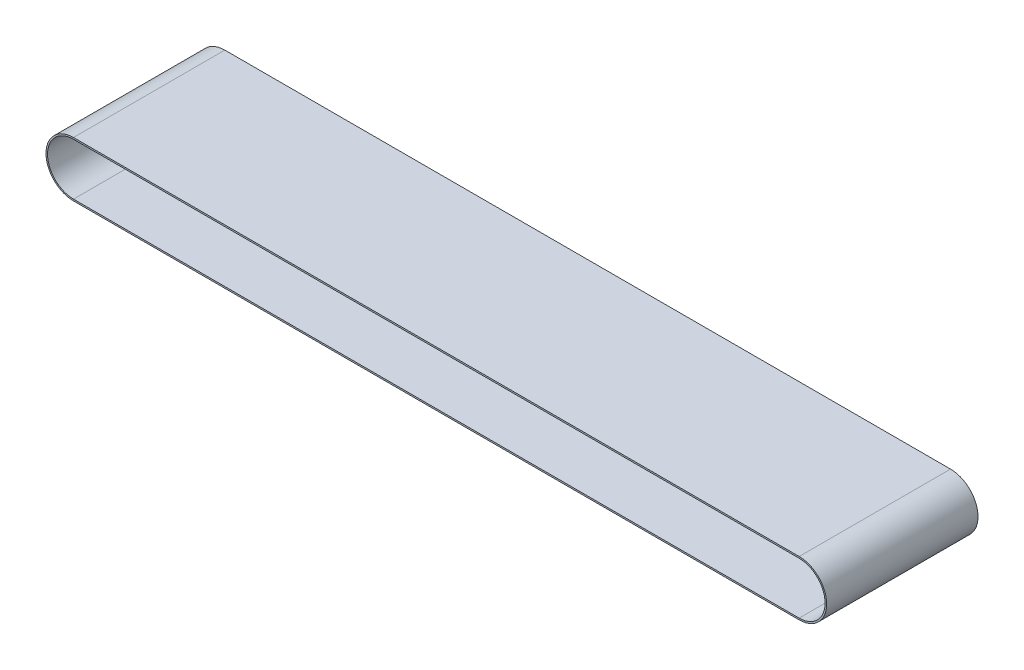
from build123d import *

# Parameters (mm, degrees)
BOSS_EXTRUDE1_DEPTH = 73


with BuildPart() as part:
    # Sketch1 → Boss-Extrude1 (new body, symmetric)
    with BuildSketch(Plane.XY):
        with BuildLine():
            Line((0, 26.5), (700, 26.5))
            ThreePointArc((700, 26.5), (726.5, 0), (700, -26.5))
            Line((700, -26.5), (0, -26.5))
            ThreePointArc((0, -26.5), (-26.5, 0), (0, 26.5))
        make_face()
        with BuildLine():
            Line((0, 25), (700, 25))
            ThreePointArc((700, 25), (725, 0), (700, -25))
            Line((700, -25), (0, -25))
            ThreePointArc((0, -25), (-25, 0), (0, 25))
        make_face(mode=Mode.SUBTRACT)
    extrude(amount=BOSS_EXTRUDE1_DEPTH, both=True)


solid = part.part
